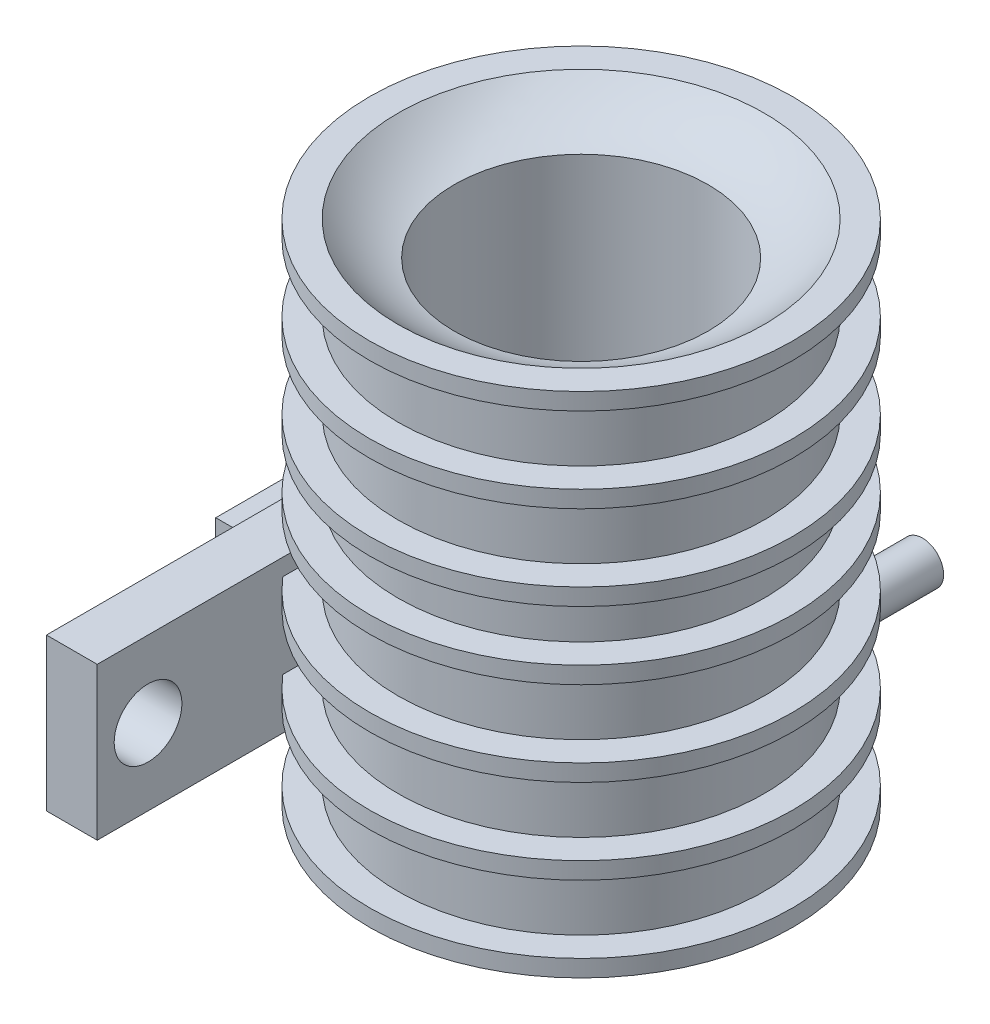
from build123d import *

# Parameters (mm, degrees)
CROQUIS2_R              = 7.5
CORTAR_EXTRUIR1_DEPTH   = 24
SALIENTE_EXTRUIR1_DEPTH = 3
SALIENTE_EXTRUIR2_DEPTH = 3
CROQUIS7_R              = 1.5
CORTAR_EXTRUIR3_DEPTH   = 13
CROQUIS8_R              = 1.5
CORTAR_EXTRUIR4_DEPTH   = 13
CROQUIS9_R              = 2.5
SALIENTE_EXTRUIR3_DEPTH = 13
CROQUIS10_R             = 1.104312036
CORTAR_EXTRUIR5_DEPTH   = 13
CROQUIS13_R             = 2.5
CROQUIS13_R_2           = 1.25
CORTAR_EXTRUIR6_DEPTH   = 5.5
CROQUIS15_W             = 10
CROQUIS15_H             = 8
SALIENTE_EXTRUIR4_DEPTH = 3
CROQUIS16_R             = 1.5
CORTAR_EXTRUIR7_DEPTH   = 30
CROQUIS17_R             = 1.5
SALIENTE_EXTRUIR5_DEPTH = 3
CROQUIS18_W             = 2
CROQUIS18_H             = 9
CORTAR_EXTRUIR11_DEPTH  = 3
CROQUIS19_R             = 2
CORTAR_EXTRUIR12_DEPTH  = 33


with BuildPart() as part:
    # Croquis1 → Revolución1 (revolve)
    with BuildSketch(Plane.XY, mode=Mode.PRIVATE) as revoluci_n1_sk:
        with BuildLine():
            Line((-10.818667505, 0), (-12.5, 0))
            Line((-12.5, 0), (-12.5, -1))
            Line((-12.5, -1), (-10.818667505, -1))
            Line((-10.818667505, -1), (-10.818667505, -5))
            Line((-10.818667505, -5), (-12.5, -5))
            Line((-12.5, -5), (-12.5, -6))
            Line((-12.5, -6), (-10.818667505, -6))
            Line((-10.818667505, -6), (-10.818667505, -10))
            Line((-10.818667505, -10), (-12.5, -10))
            Line((-12.5, -10), (-12.5, -11))
            Line((-12.5, -11), (-10.818667505, -11))
            Line((-10.818667505, -11), (-10.818667505, -14))
            Line((-10.818667505, -14), (-12.5, -14))
            Line((-12.5, -14), (-12.5, -15))
            Line((-12.5, -15), (-10.818667505, -15))
            Line((-10.818667505, -15), (-10.818667505, -19))
            Line((-10.818667505, -19), (-12.5, -19))
            Line((-12.5, -19), (-12.5, -20))
            Line((-12.5, -20), (-10.818667505, -20))
            Line((-10.818667505, -20), (-10.818667505, -24))
            Line((-10.818667505, -24), (-12.5, -24))
            Line((-12.5, -24), (-12.5, -25))
            Line((-12.5, -25), (-10.818667505, -25))
            Line((-10.818667505, -25), (-10.818667505, -29))
            Line((-10.818667505, -29), (-12.5, -29))
            Line((-12.5, -29), (-12.5, -30))
            Line((-12.5, -30), (0, -30))
            Line((0, -30), (0, -2))
            Line((0, -2), (-7.5, -2))
            add(Edge.make_bspline(
                [(-10.818667505, 0), (-9.258756579, -1.530453888), (-7.5, -2)],
                knots=[0, 0, 0, 0.398472736, 0.398472736, 0.398472736], degree=2))
        make_face()
    revolve(revoluci_n1_sk.sketch.rotate(Axis((0, -2, 0), (0, -1, 0)), 270), axis=Axis((0, -2, 0), (0, -1, 0)))

    # Croquis2 → Cortar-Extruir1 (cut)
    with BuildSketch(Plane(origin=(0, 0, 0), x_dir=(1, 0, 0), z_dir=(0, 1, 0))):
        with Locations(Location((0, 0, 0), (0, 0, 270))):
            Circle(CROQUIS2_R)
    extrude(amount=-CORTAR_EXTRUIR1_DEPTH, mode=Mode.SUBTRACT)

    # Croquis4 → Saliente-Extruir1 (add)
    with BuildSketch(Plane.ZY.offset(12.5)):
        Polygon((-8.915161304, -27), (10.818667505, -27), (21.084838696, -27), (21.084838696, -18), (-8.915161304, -18), align=None)
    extrude(amount=-SALIENTE_EXTRUIR1_DEPTH)

    # Croquis6 → Saliente-Extruir2 (add)
    with BuildSketch(Plane.XZ.offset(30)):
        Polygon((-12.5, -8.915161304), (-21.5, -8.915161304), (-21.5, -0.915161304), (-12.5, -0.915161304), (-4.999981801, -0.915161304), (-4.999981801, -8.915161304), align=None)
    extrude(amount=-SALIENTE_EXTRUIR2_DEPTH)

    # Croquis7 → Cortar-Extruir3 (cut)
    with BuildSketch(Plane.XZ.offset(30)):
        with Locations(Location((-18, -4.915161304, 0), (0, 0, 270))):
            Circle(CROQUIS7_R)
    extrude(amount=-CORTAR_EXTRUIR3_DEPTH, mode=Mode.SUBTRACT)

    # Croquis8 → Cortar-Extruir4 (cut)
    with BuildSketch(Plane.ZY.offset(12.5)):
        with Locations((17.584838696, -22.5)):
            Circle(CROQUIS8_R)
    extrude(amount=-CORTAR_EXTRUIR4_DEPTH, mode=Mode.SUBTRACT)

    # Croquis9 → Saliente-Extruir3 (add)
    with BuildSketch(Plane.XY.offset(-19.5)):
        with Locations(Location((0.659333752, -27, 0), (0, 0, 126.869897752))):
            Circle(CROQUIS9_R)
    extrude(amount=SALIENTE_EXTRUIR3_DEPTH)

    # Croquis10 → Cortar-Extruir5 (cut)
    with BuildSketch(Plane(origin=(0, 0, -19.5), x_dir=(-1, 0, 0), z_dir=(0, 0, -1))):
        with Locations((-0.659333752, -27)):
            Circle(CROQUIS10_R)
    extrude(amount=-CORTAR_EXTRUIR5_DEPTH, mode=Mode.SUBTRACT)

    # Croquis13 → Cortar-Extruir6 (cut)
    with BuildSketch(Plane(origin=(0, 0, -19.5), x_dir=(-1, 0, 0), z_dir=(0, 0, -1))):
        with Locations((-0.659333752, -27)):
            Circle(CROQUIS13_R)
        with Locations((-0.659333752, -27)):
            Circle(CROQUIS13_R_2, mode=Mode.SUBTRACT)
    extrude(amount=-CORTAR_EXTRUIR6_DEPTH, mode=Mode.SUBTRACT)

    # Croquis15 → Saliente-Extruir4 (add)
    with BuildSketch(Plane(origin=(0, -27, 0), x_dir=(1, 0, 0), z_dir=(0, 1, 0))):
        with Locations((-17.5, 4.915161304)):
            Rectangle(CROQUIS15_W, CROQUIS15_H)
    extrude(amount=-SALIENTE_EXTRUIR4_DEPTH)

    # Croquis16 → Cortar-Extruir7 (cut)
    with BuildSketch(Plane(origin=(0, -27, 0), x_dir=(1, 0, 0), z_dir=(0, 1, 0))):
        with Locations(Location((-17.5, 4.915161304, 0), (0, 0, 270))):
            Circle(CROQUIS16_R)
    extrude(amount=-CORTAR_EXTRUIR7_DEPTH, mode=Mode.SUBTRACT)

    # Croquis17 → Saliente-Extruir5 (add)
    with BuildSketch(Plane.ZY.offset(12.5)):
        Polygon((19.084838696, -18), (-8.915161304, -18), (-8.915161304, -27), (-0.915161304, -27), (19.084838696, -27), (19.084838696, -22.5), align=None)
        with Locations((17.584838696, -22.5)):
            Circle(CROQUIS17_R, mode=Mode.SUBTRACT)
        with Locations((17.584838696, -22.5)):
            Circle(CROQUIS17_R)
    extrude(amount=-SALIENTE_EXTRUIR5_DEPTH)

    # Croquis18 → Cortar-Extruir11 (cut)
    with BuildSketch(Plane.ZY.offset(12.5)):
        with Locations((20.084838696, -22.5)):
            Rectangle(CROQUIS18_W, CROQUIS18_H)
    extrude(amount=-CORTAR_EXTRUIR11_DEPTH, mode=Mode.SUBTRACT)

    # Croquis19 → Cortar-Extruir12 (cut)
    with BuildSketch(Plane.ZY.offset(12.5)):
        with Locations((16.084838696, -22.5)):
            Circle(CROQUIS19_R)
    extrude(amount=-CORTAR_EXTRUIR12_DEPTH, mode=Mode.SUBTRACT)


solid = part.part
